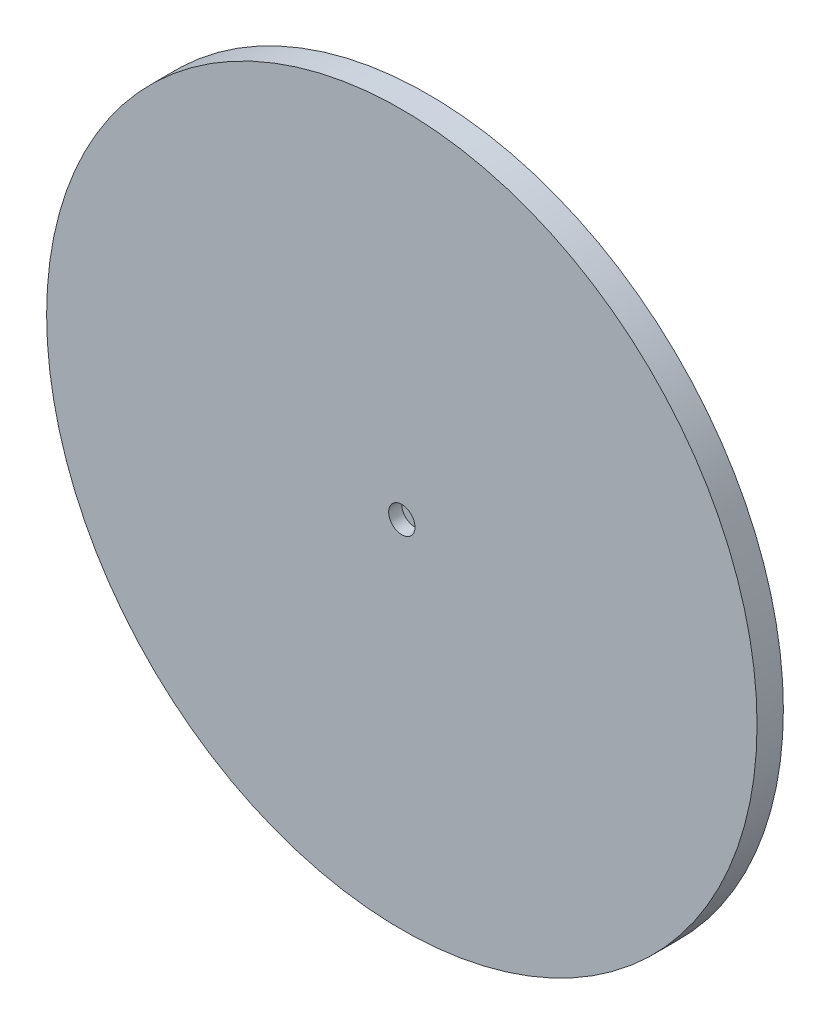
from build123d import *

# Parameters (mm, degrees)
ESBO_O1_R                = 27
RESSALTO_EXTRUS_O1_DEPTH = 2
ESBO_O3_R                = 5
RESSALTO_EXTRUS_O2_DEPTH = 1
ESBO_O4_R                = 1
CORTE_EXTRUS_O1_DEPTH    = 1


with BuildPart() as part:
    # Esboço1 → Ressalto-extrusão1 (new body)
    with BuildSketch(Plane.XY):
        Circle(ESBO_O1_R)
    extrude(amount=RESSALTO_EXTRUS_O1_DEPTH)

    # Esboço3 → Ressalto-extrusão2 (add)
    with BuildSketch(Plane(origin=(0, 0, 0), x_dir=(-1, 0, 0), z_dir=(0, 0, -1))):
        Circle(ESBO_O3_R)
    extrude(amount=RESSALTO_EXTRUS_O2_DEPTH)

    # Esboço4 → Corte-extrusão1 (cut)
    with BuildSketch(Plane.XY.offset(2)):
        Circle(ESBO_O4_R)
    extrude(amount=-CORTE_EXTRUS_O1_DEPTH, mode=Mode.SUBTRACT)


solid = part.part
